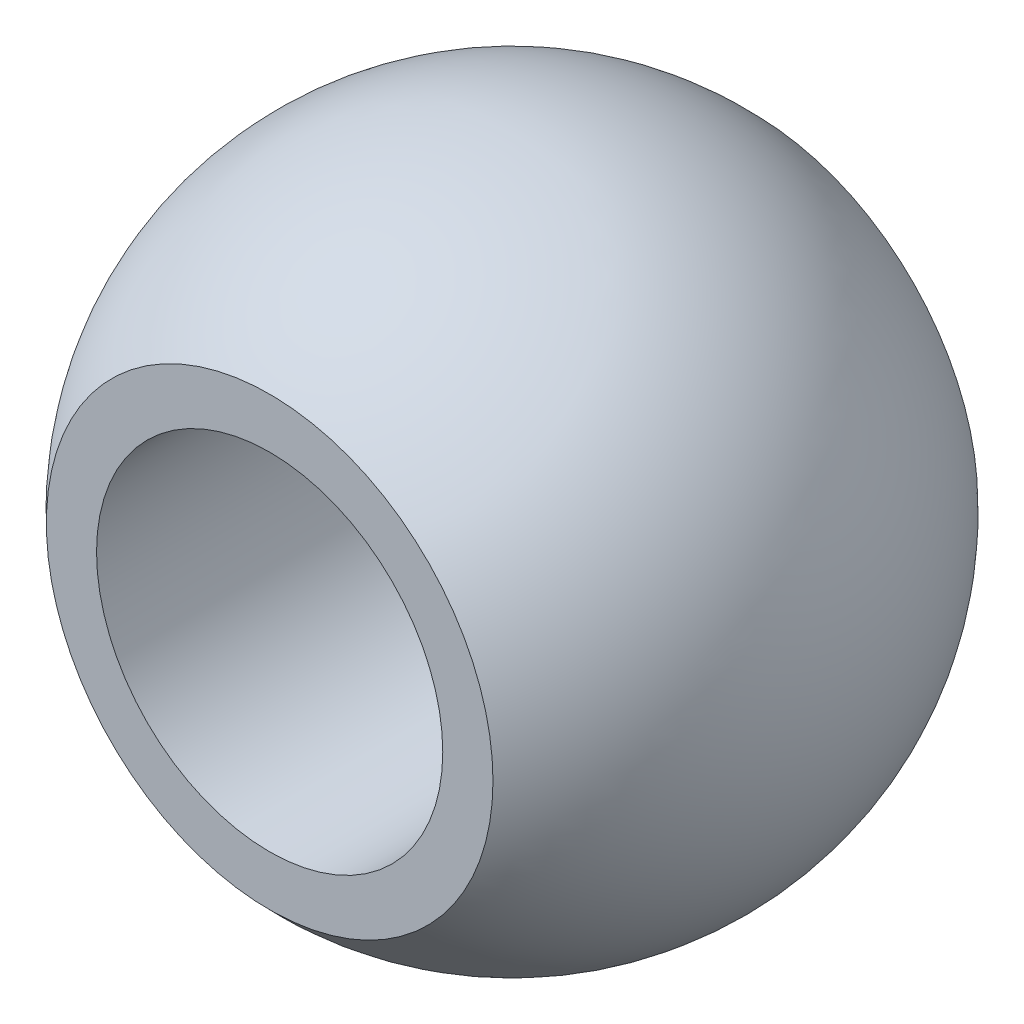
from build123d import *


with BuildPart() as part:
    # Sketch1 → Revolve1 (revolve)
    with BuildSketch(Plane(origin=(0, 0, 0), x_dir=(0, 0, -1), z_dir=(1, 0, 0))):
        with BuildLine():
            Line((-7, -6.45), (-7, -5))
            Line((-7, -5), (7, -5))
            Line((7, -5), (7, -6.45))
            ThreePointArc((7, -6.45), (0, -9.518534551), (-7, -6.45))
        make_face()
    revolve(axis=Axis((0, 0, 4.635206435), (0, 0, -1)))


solid = part.part
